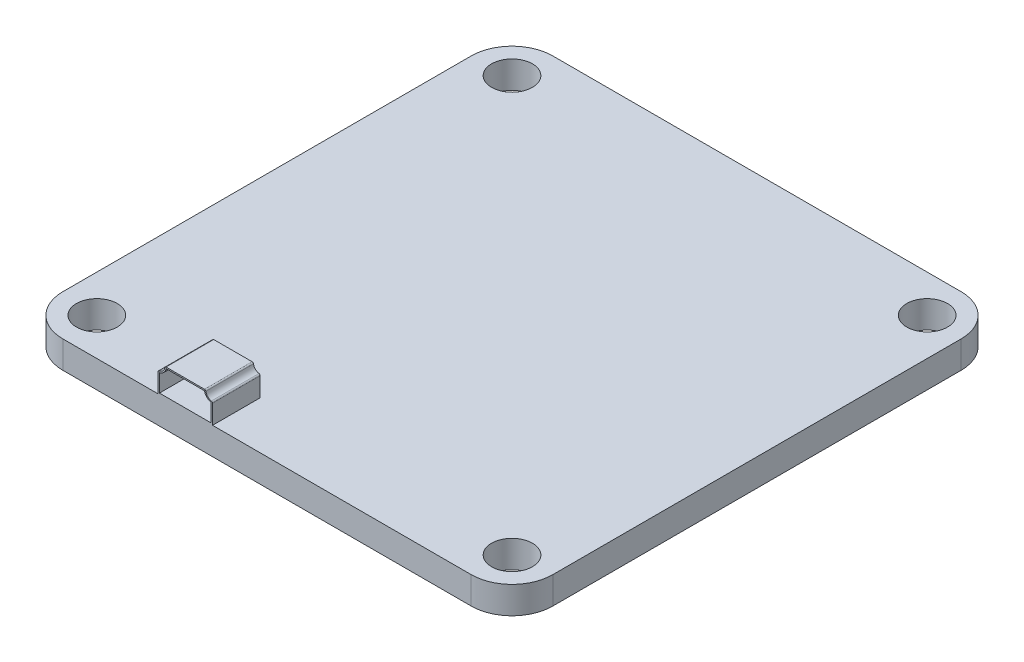
from build123d import *

# Parameters (mm, degrees)
SKETCH1_R           = 1.5
BOSS_EXTRUDE1_DEPTH = 1
BOSS_EXTRUDE2_DEPTH = 3.5
BOSS_EXTRUDE3_DEPTH = 0.5
SKETCH4_R           = 0.25
CUT_EXTRUDE1_DEPTH  = 38.70941527


with BuildPart() as part:
    # Sketch1 → Boss-Extrude1 (new, symmetric)
    with BuildSketch(Plane(origin=(0, 0, 0), x_dir=(1, 0, 0), z_dir=(0, 1, 0))):
        with BuildLine():
            Line((-15, -18), (15, -18))
            ThreePointArc((15, -18), (17.121320344, -17.121320344), (18, -15))
            Line((18, -15), (18, 15))
            ThreePointArc((18, 15), (17.121320344, 17.121320344), (15, 18))
            Line((15, 18), (-15, 18))
            ThreePointArc((-15, 18), (-17.121320344, 17.121320344), (-18, 15))
            Line((-18, 15), (-18, -15))
            ThreePointArc((-18, -15), (-17.121320344, -17.121320344), (-15, -18))
        make_face()
        with Locations(Location((15.25, 15.25, 0), (0, 0, 270))):
            Circle(SKETCH1_R, mode=Mode.SUBTRACT)
        with Locations(Location((-15.25, 15.25, 0), (0, 0, 90))):
            Circle(SKETCH1_R, mode=Mode.SUBTRACT)
        with Locations(Location((15.25, -15.25, 0), (0, 0, 90))):
            Circle(SKETCH1_R, mode=Mode.SUBTRACT)
        with Locations(Location((-15.25, -15.25, 0), (0, 0, 270))):
            Circle(SKETCH1_R, mode=Mode.SUBTRACT)
    extrude(amount=BOSS_EXTRUDE1_DEPTH, both=True)

    # Sketch2 → Boss-Extrude2 (add)
    with BuildSketch(Plane.XY.offset(18)):
        with BuildLine():
            Line((-8, 1), (-4, 1))
            Line((-4, 1), (-4, 2.408392022))
            ThreePointArc((-4, 2.408392022), (-4.023623738, 2.472941744), (-4.083333333, 2.506993351))
            ThreePointArc((-4.083333333, 2.506993351), (-4.353553391, 2.646446609), (-4.493006649, 2.916666667))
            ThreePointArc((-4.493006649, 2.916666667), (-4.527058256, 2.976376262), (-4.591607978, 3))
            Line((-4.591607978, 3), (-7.408392022, 3))
            ThreePointArc((-7.408392022, 3), (-7.472941744, 2.976376262), (-7.506993351, 2.916666667))
            ThreePointArc((-7.506993351, 2.916666667), (-7.646446609, 2.646446609), (-7.916666667, 2.506993351))
            ThreePointArc((-7.916666667, 2.506993351), (-7.976376262, 2.472941744), (-8, 2.408392022))
            Line((-8, 2.408392022), (-8, 1))
        make_face()
        with BuildLine():
            Line((-4.1, 1.1), (-4.1, 2.408392022))
            ThreePointArc((-4.1, 2.408392022), (-4.424264069, 2.575735931), (-4.591607978, 2.9))
            Line((-4.591607978, 2.9), (-7.408392022, 2.9))
            ThreePointArc((-7.408392022, 2.9), (-7.575735931, 2.575735931), (-7.9, 2.408392022))
            Line((-7.9, 2.408392022), (-7.9, 1.1))
            Line((-7.9, 1.1), (-4.1, 1.1))
        make_face(mode=Mode.SUBTRACT)
    extrude(amount=-BOSS_EXTRUDE2_DEPTH)

    # Sketch3 → Boss-Extrude3 (add)
    with BuildSketch(Plane(origin=(0, 0, 14.5), x_dir=(-1, 0, 0), z_dir=(0, 0, -1))):
        with BuildLine():
            Line((8, 1), (8, 2.408392022))
            ThreePointArc((8, 2.408392022), (7.976376262, 2.472941744), (7.916666667, 2.506993351))
            ThreePointArc((7.916666667, 2.506993351), (7.646446609, 2.646446609), (7.506993351, 2.916666667))
            ThreePointArc((7.506993351, 2.916666667), (7.472941744, 2.976376262), (7.408392022, 3))
            Line((7.408392022, 3), (4.591607978, 3))
            ThreePointArc((4.591607978, 3), (4.527058256, 2.976376262), (4.493006649, 2.916666667))
            ThreePointArc((4.493006649, 2.916666667), (4.353553391, 2.646446609), (4.083333333, 2.506993351))
            ThreePointArc((4.083333333, 2.506993351), (4.023623738, 2.472941744), (4, 2.408392022))
            Line((4, 2.408392022), (4, 1))
            Line((4, 1), (8, 1))
        make_face()
    extrude(amount=-BOSS_EXTRUDE3_DEPTH)

    # Sketch4 → Cut-Extrude1 (cut, through all)
    with BuildSketch(Plane.XY.offset(15)):
        with Locations((-7, 2.6)):
            Circle(SKETCH4_R)
        with Locations((-6, 2.6)):
            Circle(SKETCH4_R)
        with Locations((-5, 2.6)):
            Circle(SKETCH4_R)
    extrude(amount=-CUT_EXTRUDE1_DEPTH, mode=Mode.SUBTRACT)


solid = part.part
